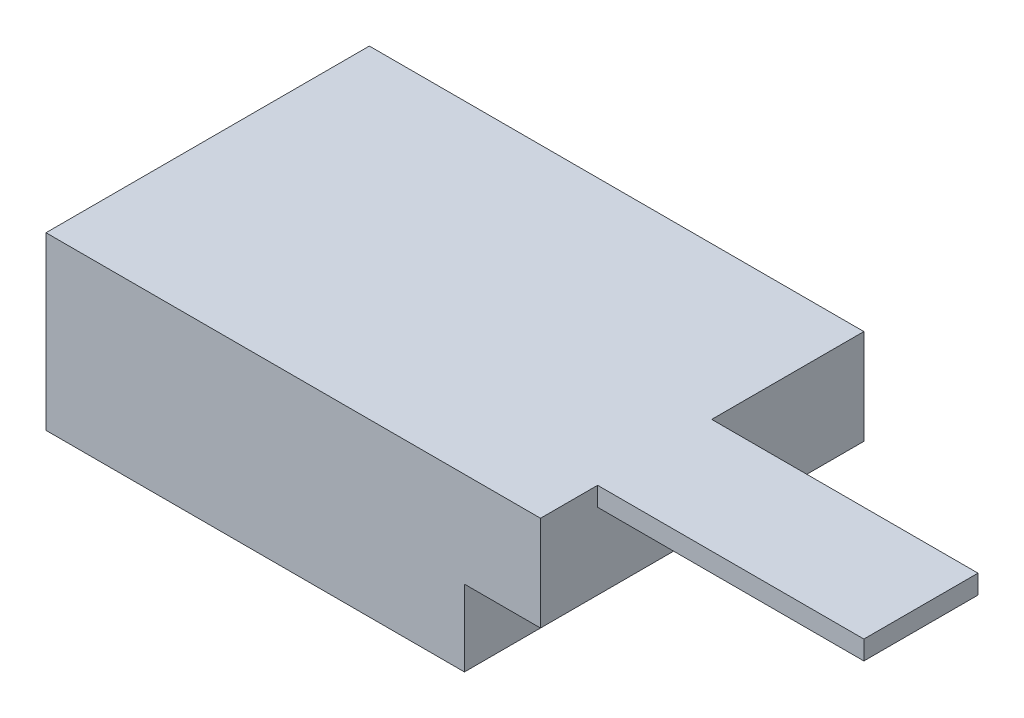
from build123d import *

# Parameters (mm, degrees)
SKETCH1_W           = 82.55
SKETCH1_H           = 53.975
BOSS_EXTRUDE1_DEPTH = 28.575
SKETCH2_W           = 12.7
SKETCH2_H           = 12.7
CUT_EXTRUDE1_DEPTH  = 54.975
SKETCH3_W           = 44.45
SKETCH3_H           = 19.05
BOSS_EXTRUDE2_DEPTH = 3.175


with BuildPart() as part:
    # Sketch1 → Boss-Extrude1 (new body)
    with BuildSketch(Plane(origin=(0, 0, 0), x_dir=(1, 0, 0), z_dir=(0, 1, 0))):
        Rectangle(SKETCH1_W, SKETCH1_H)
    extrude(amount=BOSS_EXTRUDE1_DEPTH)

    # Sketch2 → Cut-Extrude1 (cut, through all)
    with BuildSketch(Plane.XY.offset(26.9875)):
        with Locations((34.925, 6.35)):
            Rectangle(SKETCH2_W, SKETCH2_H)
    extrude(amount=-CUT_EXTRUDE1_DEPTH, mode=Mode.SUBTRACT)

    # Sketch3 → Boss-Extrude2 (add)
    with BuildSketch(Plane(origin=(0, 28.575, 0), x_dir=(1, 0, 0), z_dir=(0, 1, 0))):
        with Locations((63.5, -7.9375)):
            Rectangle(SKETCH3_W, SKETCH3_H)
    extrude(amount=-BOSS_EXTRUDE2_DEPTH)


solid = part.part
